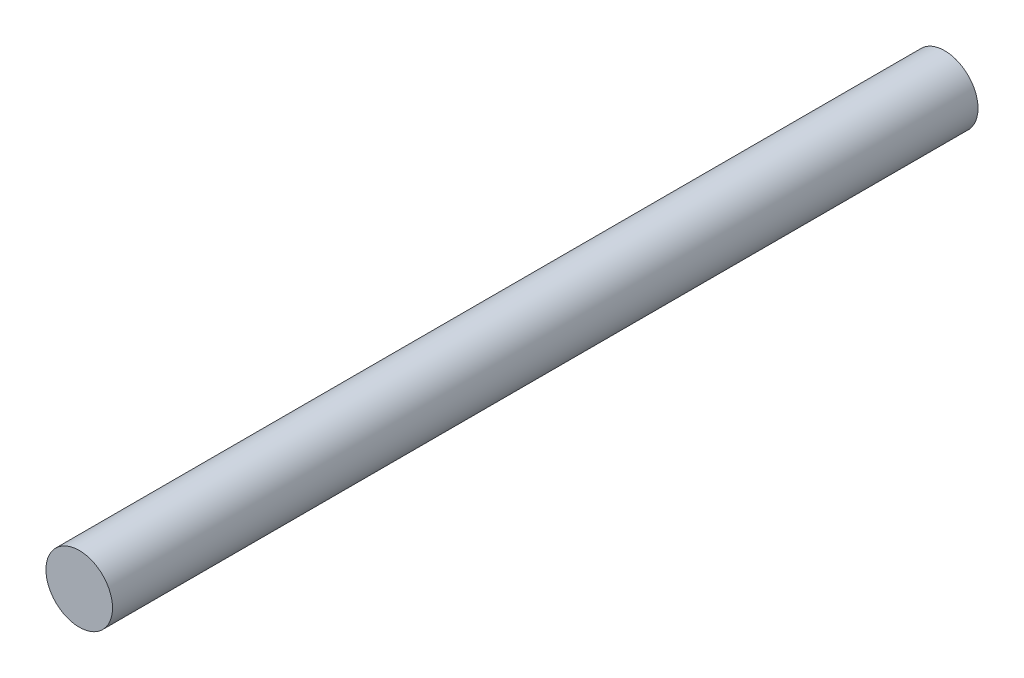
from build123d import *

# Parameters (mm, degrees)
SKETCH2_R           = 6.35
BOSS_EXTRUDE1_DEPTH = 165.1


with BuildPart() as part:
    # Sketch2 → Boss-Extrude1 (new body)
    with BuildSketch(Plane.XY):
        Circle(SKETCH2_R)
    extrude(amount=BOSS_EXTRUDE1_DEPTH)


solid = part.part
